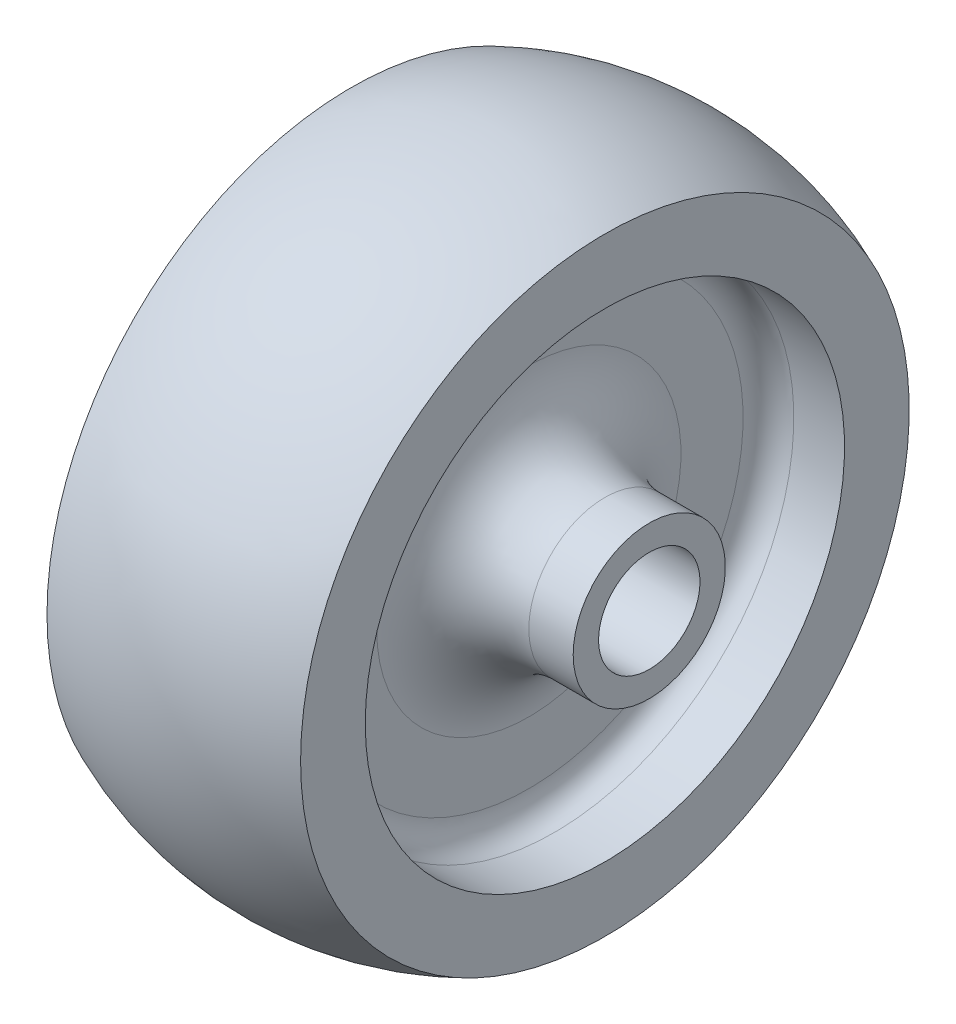
from build123d import *

# Parameters (mm, degrees)
FILLET1_R    = 6
SCALE1_SCALE = 0.5


with BuildPart() as part:
    # Sketch1 → Revolve1 (revolve)
    with BuildSketch(Plane.XY):
        with BuildLine():
            Line((0, 4), (0, 6))
            Line((0, 6), (3.5, 6))
            Line((3.5, 6), (9.5, 6))
            Line((9.5, 6), (9.5, 16.9))
            ThreePointArc((9.5, 16.9), (8.914213562, 18.314213562), (7.5, 18.9))
            Line((7.5, 18.9), (3.5, 18.9))
            Line((3.5, 18.9), (3.5, 24))
            ThreePointArc((3.5, 24), (13.5, 26.087121525), (23.5, 24))
            Line((23.5, 24), (23.5, 18.9))
            Line((23.5, 18.9), (19.5, 18.9))
            ThreePointArc((19.5, 18.9), (18.085786438, 18.314213562), (17.5, 16.9))
            Line((17.5, 16.9), (17.5, 6))
            Line((17.5, 6), (23.5, 6))
            Line((23.5, 6), (27, 6))
            Line((27, 6), (27, 4))
            Line((27, 4), (0, 4))
        make_face()
    revolve(axis=Axis((0, 0, 0), (1, 0, 0)))

    # Fillet1
    fillet1_edges = [part.edges().sort_by_distance(p)[0] for p in [
        (9.5, -6, 0),
        (17.5, -6, 0),
    ]]
    fillet(fillet1_edges, radius=FILLET1_R)


with BuildPart() as part_1:
    # Scale1: scaled about (0, 0, 0)
    add(part.part.scale(SCALE1_SCALE))


solid = part_1.part
